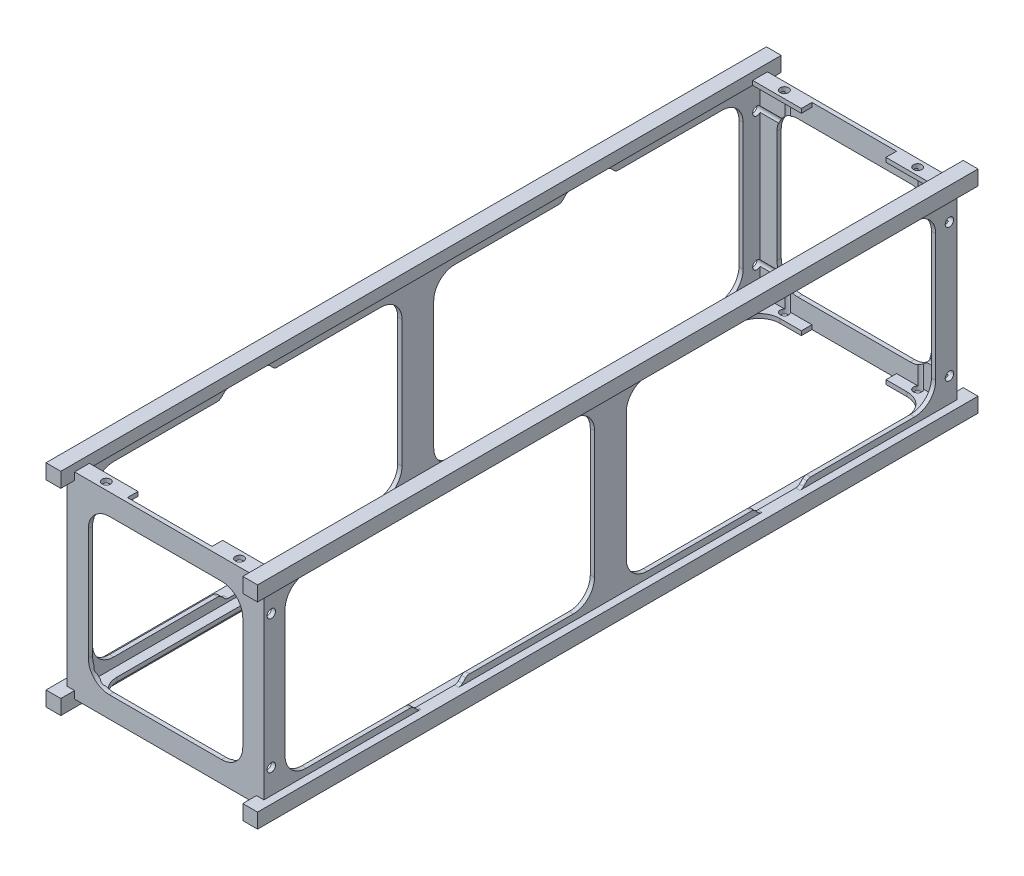
from build123d import *

# Parameters (mm, degrees)
SKETCH1_W                   = 10
SKETCH1_H                   = 10
RAIL_PROFILE_DEPTH          = 34.05
RAILS_THICKNESS_DEPTH       = 34.05
WALLS_DEPTH                 = 32.75
HOLE_IN_SQUARE_WALL_DEPTH   = 32.75
HOLE_IN_LONG_WALL_DEPTH     = 9.3
HOLES_IN_LONEG_WALL_2_DEPTH = 9.3
CREATE_START                = -32.35
SKETCH12_W                  = 8.9
SKETCH12_H                  = 8.9
CREATE_INNER_VOLUME_DEPTH   = 32.35
SKETCH15_W                  = 8.6
SKETCH15_H                  = 31.35
CUT_TO_OPEN_ONE_SIDE_DEPTH  = 0.2
SKETCH16_R                  = 0.2
CUT_EXTRUDE2_DEPTH          = 9.3
SKETCH17_R                  = 0.2
CUT_EXTRUDE3_DEPTH          = 9.3
SCALE1_SCALE                = 10


with BuildPart() as part:
    # Sketch1 → Rail profile (new body)
    with BuildSketch(Plane.XY):
        with Locations((5, 5)):
            Rectangle(SKETCH1_W, SKETCH1_H)
    extrude(amount=RAIL_PROFILE_DEPTH)

    # Sketch2 → Rails thickness (cut)
    with BuildSketch(Plane(origin=(0, 0, 0), x_dir=(-1, 0, 0), z_dir=(0, 0, -1))):
        Polygon((-10, 9.3), (-10, 0.7), (-9.3, 0.7), (-9.3, 0), (-0.7, 0), (-0.7, 0.7), (0, 0.7), (0, 9.3), (-0.7, 9.3), (-0.7, 10), (-9.3, 10), (-9.3, 9.3), align=None)
    extrude(amount=-RAILS_THICKNESS_DEPTH, mode=Mode.SUBTRACT)

    # Sketch4 → Walls (add)
    with BuildSketch(Plane(origin=(0, 0, 0.65), x_dir=(-1, 0, 0), z_dir=(0, 0, -1))):
        Polygon((-9.3, 9.65), (-9.3, 9.3), (-9.65, 9.3), (-9.65, 0.7), (-9.3, 0.7), (-9.3, 0.35), (-0.7, 0.35), (-0.7, 0.7), (-0.35, 0.7), (-0.35, 9.3), (-0.7, 9.3), (-0.7, 9.65), align=None)
    extrude(amount=-WALLS_DEPTH)

    # Sketch7 → Hole in square wall (cut)
    with BuildSketch(Plane(origin=(0, 0, 0.65), x_dir=(-1, 0, 0), z_dir=(0, 0, -1))):
        with BuildLine():
            Line((-7.65, 8.65), (-2.35, 8.65))
            ThreePointArc((-2.35, 8.65), (-1.642893219, 8.357106781), (-1.35, 7.65))
            Line((-1.35, 7.65), (-1.35, 2.35))
            ThreePointArc((-1.35, 2.35), (-1.642893219, 1.642893219), (-2.35, 1.35))
            Line((-2.35, 1.35), (-7.65, 1.35))
            ThreePointArc((-7.65, 1.35), (-8.357106781, 1.642893219), (-8.65, 2.35))
            Line((-8.65, 2.35), (-8.65, 7.65))
            ThreePointArc((-8.65, 7.65), (-8.357106781, 8.357106781), (-7.65, 8.65))
        make_face()
    extrude(amount=-HOLE_IN_SQUARE_WALL_DEPTH, mode=Mode.SUBTRACT)

    # Sketch9 → Hole in long wall (cut)
    with BuildSketch(Plane(origin=(0, 9.65, 0), x_dir=(1, 0, 0), z_dir=(0, 1, 0))):
        with BuildLine():
            Line((3, -1.35), (3, -0.85))
            Line((3, -0.85), (7, -0.85))
            Line((7, -0.85), (7, -1.35))
            Line((7, -1.35), (8, -1.35))
            ThreePointArc((8, -1.35), (8.707106781, -1.642893219), (9, -2.35))
            Line((9, -2.35), (9, -31.7))
            ThreePointArc((9, -31.7), (8.707106781, -32.407106781), (8, -32.7))
            Line((8, -32.7), (7, -32.7))
            Line((7, -32.7), (7, -33.2))
            Line((7, -33.2), (3, -33.2))
            Line((3, -33.2), (3, -32.7))
            Line((3, -32.7), (2, -32.7))
            ThreePointArc((2, -32.7), (1.292893219, -32.407106781), (1, -31.7))
            Line((1, -31.7), (1, -2.35))
            ThreePointArc((1, -2.35), (1.292893219, -1.642893219), (2, -1.35))
            Line((2, -1.35), (3, -1.35))
        make_face()
    extrude(amount=-HOLE_IN_LONG_WALL_DEPTH, mode=Mode.SUBTRACT)

    # Sketch14 → Holes in loneg wall 2 (cut)
    with BuildSketch(Plane(origin=(9.65, 0, 0), x_dir=(0, 0, -1), z_dir=(1, 0, 0))):
        with BuildLine():
            Line((-18.775, 1), (-23.683946609, 1))
            ThreePointArc((-23.683946609, 1), (-23.779617467, 0.980969883), (-23.860723305, 0.926776695))
            Line((-23.860723305, 0.926776695), (-24.014276695, 0.773223305))
            ThreePointArc((-24.014276695, 0.773223305), (-24.095382533, 0.719030117), (-24.191053391, 0.7))
            Line((-24.191053391, 0.7), (-25.0875, 0.7))
            Line((-25.0875, 0.7), (-25.983946609, 0.7))
            ThreePointArc((-25.983946609, 0.7), (-26.079617467, 0.719030117), (-26.160723305, 0.773223305))
            Line((-26.160723305, 0.773223305), (-26.314276695, 0.926776695))
            ThreePointArc((-26.314276695, 0.926776695), (-26.395382533, 0.980969883), (-26.491053391, 1))
            Line((-26.491053391, 1), (-31.4, 1))
            ThreePointArc((-31.4, 1), (-32.107106781, 1.292893219), (-32.4, 2))
            Line((-32.4, 2), (-32.4, 8))
            ThreePointArc((-32.4, 8), (-32.107106781, 8.707106781), (-31.4, 9))
            Line((-31.4, 9), (-26.491053391, 9))
            ThreePointArc((-26.491053391, 9), (-26.395382533, 9.019030117), (-26.314276695, 9.073223305))
            Line((-26.314276695, 9.073223305), (-26.160723305, 9.226776695))
            ThreePointArc((-26.160723305, 9.226776695), (-26.079617467, 9.280969883), (-25.983946609, 9.3))
            Line((-25.983946609, 9.3), (-25.0875, 9.3))
            Line((-25.0875, 9.3), (-24.191053391, 9.3))
            ThreePointArc((-24.191053391, 9.3), (-24.095382533, 9.280969883), (-24.014276695, 9.226776695))
            Line((-24.014276695, 9.226776695), (-23.860723305, 9.073223305))
            ThreePointArc((-23.860723305, 9.073223305), (-23.779617467, 9.019030117), (-23.683946609, 9))
            Line((-23.683946609, 9), (-18.775, 9))
            ThreePointArc((-18.775, 9), (-18.067893219, 8.707106781), (-17.775, 8))
            Line((-17.775, 8), (-17.775, 2))
            ThreePointArc((-17.775, 2), (-18.067893219, 1.292893219), (-18.775, 1))
        make_face()
        with BuildLine():
            Line((-16.275, 2), (-16.275, 8))
            ThreePointArc((-16.275, 8), (-15.982106781, 8.707106781), (-15.275, 9))
            Line((-15.275, 9), (-10.366053391, 9))
            ThreePointArc((-10.366053391, 9), (-10.270382533, 9.019030117), (-10.189276695, 9.073223305))
            Line((-10.189276695, 9.073223305), (-10.035723305, 9.226776695))
            ThreePointArc((-10.035723305, 9.226776695), (-9.954617467, 9.280969883), (-9.858946609, 9.3))
            Line((-9.858946609, 9.3), (-8.9625, 9.3))
            Line((-8.9625, 9.3), (-8.066053391, 9.3))
            ThreePointArc((-8.066053391, 9.3), (-7.970382533, 9.280969883), (-7.889276695, 9.226776695))
            Line((-7.889276695, 9.226776695), (-7.735723305, 9.073223305))
            ThreePointArc((-7.735723305, 9.073223305), (-7.654617467, 9.019030117), (-7.558946609, 9))
            Line((-7.558946609, 9), (-2.65, 9))
            ThreePointArc((-2.65, 9), (-1.942893219, 8.707106781), (-1.65, 8))
            Line((-1.65, 8), (-1.65, 2))
            ThreePointArc((-1.65, 2), (-1.942893219, 1.292893219), (-2.65, 1))
            Line((-2.65, 1), (-7.558946609, 1))
            ThreePointArc((-7.558946609, 1), (-7.654617467, 0.980969883), (-7.735723305, 0.926776695))
            Line((-7.735723305, 0.926776695), (-7.889276695, 0.773223305))
            ThreePointArc((-7.889276695, 0.773223305), (-7.970382533, 0.719030117), (-8.066053391, 0.7))
            Line((-8.066053391, 0.7), (-8.9625, 0.7))
            Line((-8.9625, 0.7), (-9.858946609, 0.7))
            ThreePointArc((-9.858946609, 0.7), (-9.954617467, 0.719030117), (-10.035723305, 0.773223305))
            Line((-10.035723305, 0.773223305), (-10.189276695, 0.926776695))
            ThreePointArc((-10.189276695, 0.926776695), (-10.270382533, 0.980969883), (-10.366053391, 1))
            Line((-10.366053391, 1), (-15.275, 1))
            ThreePointArc((-15.275, 1), (-15.982106781, 1.292893219), (-16.275, 2))
        make_face()
    extrude(amount=-HOLES_IN_LONEG_WALL_2_DEPTH, mode=Mode.SUBTRACT)

    # Sketch12 → Create inner volume (cut)
    with BuildSketch(Plane.XY.offset(33.2).offset(CREATE_START)):
        with Locations((5, 5)):
            Rectangle(SKETCH12_W, SKETCH12_H)
    extrude(amount=CREATE_INNER_VOLUME_DEPTH, mode=Mode.SUBTRACT)

    # Sketch15 → Cut to open one side (cut)
    with BuildSketch(Plane(origin=(0, 9.65, 0), x_dir=(1, 0, 0), z_dir=(0, 1, 0))):
        with Locations((5, -17.025)):
            Rectangle(SKETCH15_W, SKETCH15_H)
    extrude(amount=-CUT_TO_OPEN_ONE_SIDE_DEPTH, mode=Mode.SUBTRACT)

    # Sketch16 → Cut-Extrude2 (cut)
    with BuildSketch(Plane(origin=(0, 9.65, 0), x_dir=(1, 0, 0), z_dir=(0, 1, 0))):
        with Locations((1.85, -1)):
            Circle(SKETCH16_R)
        with Locations((8.15, -1)):
            Circle(SKETCH16_R)
        with Locations((8.15, -33.05)):
            Circle(SKETCH16_R)
        with Locations((1.85, -33.05)):
            Circle(SKETCH16_R)
    extrude(amount=-CUT_EXTRUDE2_DEPTH, mode=Mode.SUBTRACT)

    # Sketch17 → Cut-Extrude3 (cut)
    with BuildSketch(Plane(origin=(9.65, 0, 0), x_dir=(0, 0, -1), z_dir=(1, 0, 0))):
        with Locations((-33.05, 8.15)):
            Circle(SKETCH17_R)
        with Locations((-33.05, 1.85)):
            Circle(SKETCH17_R)
        with Locations((-1, 1.85)):
            Circle(SKETCH17_R)
        with Locations((-1, 8.15)):
            Circle(SKETCH17_R)
    extrude(amount=-CUT_EXTRUDE3_DEPTH, mode=Mode.SUBTRACT)


with BuildPart() as part_1:
    # Scale1: scaled about (5.000000069, 4.820580183, 17.024999987)
    add(part.part.scale(SCALE1_SCALE).moved(Location((-45.000000621, -43.385221647, -153.224999883))))


solid = part_1.part
